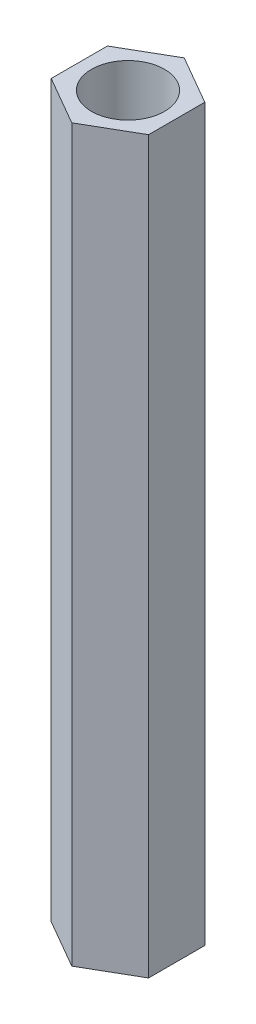
from build123d import *

# Parameters (mm, degrees)
SKETCH_1_R      = 1.5
EXTRUDE_1_DEPTH = 30


with BuildPart() as part:
    # 草图1 → 凸台-拉伸1 (new body)
    with BuildSketch(Plane(origin=(0, 0, 0), x_dir=(1, 0, 0), z_dir=(0, 1, 0))):
        Polygon((0, 2.309401077), (-2, 1.154700538), (-2, -1.154700538), (0, -2.309401077), (2, -1.154700538), (2, 1.154700538), align=None)
        Circle(SKETCH_1_R, mode=Mode.SUBTRACT)
    extrude(amount=EXTRUDE_1_DEPTH)


solid = part.part
